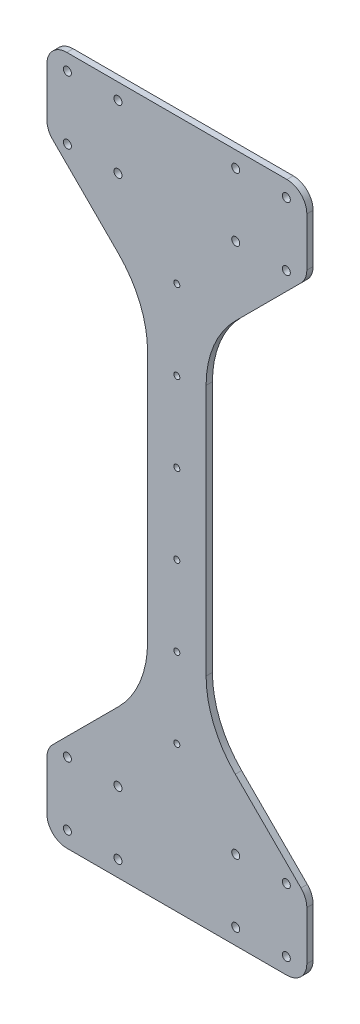
from build123d import *

# Parameters (mm, degrees)
BOSS_EXTRUDE1_DEPTH = 3.175
CUT_EXTRUDE1_DEPTH  = 10
SKETCH3_R           = 2.0193
BOSS_EXTRUDE2_DEPTH = 3.175
FILLET1_R           = 10
FILLET2_R           = 50
SKETCH4_R           = 2.02
CUT_EXTRUDE2_DEPTH  = 10
SKETCH5_R           = 1.5
CUT_EXTRUDE3_DEPTH  = 10


with BuildPart() as part:
    # Sketch1 → Boss-Extrude1 (new body)
    with BuildSketch(Plane.XY):
        Polygon((165.934536959, -16.66935), (157.315236959, -8.05005), (115.359952094, -8.05005), (89.959952094, -8.05005), (48.004667228, -8.05005), (39.385367228, -16.66935), (39.385367228, -40.05005), (39.385367228, -52.41105), (165.934536959, -56.67505), (165.934536959, -42.05005), align=None)
        with BuildLine():
            ThreePointArc((47.685367228, -44.38075), (49.704667228, -46.40005), (47.685367228, -48.41935))
            ThreePointArc((47.685367228, -48.41935), (45.666067228, -46.40005), (47.685367228, -44.38075))
        make_face(mode=Mode.SUBTRACT)
        with BuildLine():
            ThreePointArc((47.685367228, -12.63075), (49.704667228, -14.65005), (47.685367228, -16.66935))
            ThreePointArc((47.685367228, -16.66935), (45.666067228, -14.65005), (47.685367228, -12.63075))
        make_face(mode=Mode.SUBTRACT)
        with BuildLine():
            ThreePointArc((73.085367228, -44.38075), (75.104667228, -46.40005), (73.085367228, -48.41935))
            ThreePointArc((73.085367228, -48.41935), (71.066067228, -46.40005), (73.085367228, -44.38075))
        make_face(mode=Mode.SUBTRACT)
        with BuildLine():
            ThreePointArc((73.085367228, -12.63075), (75.104667228, -14.65005), (73.085367228, -16.66935))
            ThreePointArc((73.085367228, -16.66935), (71.066067228, -14.65005), (73.085367228, -12.63075))
        make_face(mode=Mode.SUBTRACT)
        with BuildLine():
            ThreePointArc((132.234536959, -44.38075), (134.253836959, -46.40005), (132.234536959, -48.41935))
            ThreePointArc((132.234536959, -48.41935), (130.215236959, -46.40005), (132.234536959, -44.38075))
        make_face(mode=Mode.SUBTRACT)
        with BuildLine():
            ThreePointArc((132.234536959, -12.63075), (134.253836959, -14.65005), (132.234536959, -16.66935))
            ThreePointArc((132.234536959, -16.66935), (130.215236959, -14.65005), (132.234536959, -12.63075))
        make_face(mode=Mode.SUBTRACT)
        with BuildLine():
            ThreePointArc((157.634536959, -44.38075), (159.653836959, -46.40005), (157.634536959, -48.41935))
            ThreePointArc((157.634536959, -48.41935), (155.615236959, -46.40005), (157.634536959, -44.38075))
        make_face(mode=Mode.SUBTRACT)
        with BuildLine():
            ThreePointArc((157.634536959, -12.63075), (159.653836959, -14.65005), (157.634536959, -16.66935))
            ThreePointArc((157.634536959, -16.66935), (155.615236959, -14.65005), (157.634536959, -12.63075))
        make_face(mode=Mode.SUBTRACT)
        Polygon((115.359952094, -8.05005), (157.315236959, -8.05005), (115.359952094, 33.905234866), align=None)
        Polygon((89.959952094, -8.05005), (115.359952094, -8.05005), (115.359952094, 33.905234866), (115.359952094, 203.394265134), (115.359952094, 245.34955), (89.959952094, 245.34955), (89.959952094, 203.394265134), (89.959952094, 33.905234866), align=None)
        Polygon((48.004667228, -8.05005), (89.959952094, -8.05005), (89.959952094, 33.905234866), align=None)
        Polygon((89.959952094, 245.34955), (115.359952094, 245.34955), (157.315236959, 245.34955), (165.934536959, 253.96885), (165.934536959, 279.34955), (165.934536959, 293.97455), (39.385367228, 289.71055), (39.385367228, 277.34955), (39.385367228, 253.96885), (48.004667228, 245.34955), align=None)
        with BuildLine():
            ThreePointArc((47.685367228, 253.96885), (49.704667228, 251.94955), (47.685367228, 249.93025))
            ThreePointArc((47.685367228, 249.93025), (45.666067228, 251.94955), (47.685367228, 253.96885))
        make_face(mode=Mode.SUBTRACT)
        with BuildLine():
            ThreePointArc((47.685367228, 285.71885), (49.704667228, 283.69955), (47.685367228, 281.68025))
            ThreePointArc((47.685367228, 281.68025), (45.666067228, 283.69955), (47.685367228, 285.71885))
        make_face(mode=Mode.SUBTRACT)
        with BuildLine():
            ThreePointArc((73.085367228, 253.96885), (75.104667228, 251.94955), (73.085367228, 249.93025))
            ThreePointArc((73.085367228, 249.93025), (71.066067228, 251.94955), (73.085367228, 253.96885))
        make_face(mode=Mode.SUBTRACT)
        with BuildLine():
            ThreePointArc((73.085367228, 285.71885), (75.104667228, 283.69955), (73.085367228, 281.68025))
            ThreePointArc((73.085367228, 281.68025), (71.066067228, 283.69955), (73.085367228, 285.71885))
        make_face(mode=Mode.SUBTRACT)
        with BuildLine():
            ThreePointArc((132.234536959, 253.96885), (134.253836959, 251.94955), (132.234536959, 249.93025))
            ThreePointArc((132.234536959, 249.93025), (130.215236959, 251.94955), (132.234536959, 253.96885))
        make_face(mode=Mode.SUBTRACT)
        with BuildLine():
            ThreePointArc((157.634536959, 253.96885), (159.653836959, 251.94955), (157.634536959, 249.93025))
            ThreePointArc((157.634536959, 249.93025), (155.615236959, 251.94955), (157.634536959, 253.96885))
        make_face(mode=Mode.SUBTRACT)
        with BuildLine():
            ThreePointArc((157.634536959, 285.71885), (159.653836959, 283.69955), (157.634536959, 281.68025))
            ThreePointArc((157.634536959, 281.68025), (155.615236959, 283.69955), (157.634536959, 285.71885))
        make_face(mode=Mode.SUBTRACT)
        Polygon((115.359952094, 245.34955), (115.359952094, 203.394265134), (157.315236959, 245.34955), align=None)
        Polygon((48.004667228, 245.34955), (89.959952094, 203.394265134), (89.959952094, 245.34955), align=None)
    extrude(amount=BOSS_EXTRUDE1_DEPTH)

    # Sketch2 → Cut-Extrude1 (cut)
    with BuildSketch(Plane.XY.offset(3.175)):
        Polygon((84.385367228, -52.41105), (39.385367228, -52.41105), (165.934536959, -56.67505), (165.934536959, -52.41105), (120.934536959, -52.41105), align=None)
        Polygon((120.934536959, 289.71055), (165.934536959, 289.71055), (165.934536959, 293.97455), (39.385367228, 289.71055), (84.385367228, 289.71055), align=None)
    extrude(amount=-CUT_EXTRUDE1_DEPTH, mode=Mode.SUBTRACT)

    # Sketch3 → Boss-Extrude2 (add)
    with BuildSketch(Plane.XY.offset(3.175)):
        Polygon((37.385367228, -15.840922875), (37.385367228, -54.41105), (167.934536959, -54.41105), (167.934536959, -15.840922875), (117.359952094, 34.73366199), (117.359952094, 202.56583801), (167.934536959, 253.140422875), (167.934536959, 291.71055), (37.385367228, 291.71055), (37.385367228, 253.140422875), (87.959952094, 202.56583801), (87.959952094, 34.73366199), align=None)
        with Locations((132.234536959, -46.40005)):
            Circle(SKETCH3_R, mode=Mode.SUBTRACT)
        with Locations((132.234536959, -14.65005)):
            Circle(SKETCH3_R, mode=Mode.SUBTRACT)
        with Locations((47.685367228, -14.65005)):
            Circle(SKETCH3_R, mode=Mode.SUBTRACT)
        with Locations((47.685367228, -46.40005)):
            Circle(SKETCH3_R, mode=Mode.SUBTRACT)
        with Locations((73.085367228, -46.40005)):
            Circle(SKETCH3_R, mode=Mode.SUBTRACT)
        with Locations((73.085367228, -14.65005)):
            Circle(SKETCH3_R, mode=Mode.SUBTRACT)
        with Locations((157.634536959, -14.65005)):
            Circle(SKETCH3_R, mode=Mode.SUBTRACT)
        with Locations((157.634536959, -46.40005)):
            Circle(SKETCH3_R, mode=Mode.SUBTRACT)
        with Locations((132.234536959, 251.94955)):
            Circle(SKETCH3_R, mode=Mode.SUBTRACT)
        with Locations((73.085367228, 251.94955)):
            Circle(SKETCH3_R, mode=Mode.SUBTRACT)
        with Locations((157.634536959, 251.94955)):
            Circle(SKETCH3_R, mode=Mode.SUBTRACT)
        with Locations((47.685367228, 251.94955)):
            Circle(SKETCH3_R, mode=Mode.SUBTRACT)
        with Locations((47.685367228, 283.69955)):
            Circle(SKETCH3_R, mode=Mode.SUBTRACT)
        with Locations((73.085367228, 283.69955)):
            Circle(SKETCH3_R, mode=Mode.SUBTRACT)
        with Locations((157.634536959, 283.69955)):
            Circle(SKETCH3_R, mode=Mode.SUBTRACT)
    extrude(amount=-BOSS_EXTRUDE2_DEPTH)

    # Fillet1
    fillet1_edges = [part.edges().sort_by_distance(p)[0] for p in [
        (37.385367228, -54.41105, 1.5875),
        (167.934536959, -54.41105, 1.5875),
        (167.934536959, -15.840922875, 1.5875),
        (167.934536959, 253.140422875, 1.5875),
        (167.934536959, 291.71055, 1.5875),
        (37.385367228, 291.71055, 1.5875),
        (37.385367228, 253.140422875, 1.5875),
        (37.385367228, -15.840922875, 1.5875),
    ]]
    fillet(fillet1_edges, radius=FILLET1_R)

    # Fillet2
    fillet2_edges = [part.edges().sort_by_distance(p)[0] for p in [
        (117.359952094, 34.73366199, 1.5875),
        (117.359952094, 202.56583801, 1.5875),
        (87.959952094, 202.56583801, 1.5875),
        (87.959952094, 34.73366199, 1.5875),
    ]]
    fillet(fillet2_edges, radius=FILLET2_R)

    # Sketch4 → Cut-Extrude2 (cut)
    with BuildSketch(Plane.XY.offset(3.175)):
        with Locations((132.234536959, 283.69955)):
            Circle(SKETCH4_R)
    extrude(amount=-CUT_EXTRUDE2_DEPTH, mode=Mode.SUBTRACT)

    # Sketch5 → Cut-Extrude3 (cut)
    with BuildSketch(Plane(origin=(0, 0, 0), x_dir=(-1, 0, 0), z_dir=(0, 0, -1))):
        with Locations((-102.659952094, 58.64975)):
            Circle(SKETCH5_R)
        with Locations((-102.659952094, 98.64975)):
            Circle(SKETCH5_R)
        with Locations((-102.659952094, 138.64975)):
            Circle(SKETCH5_R)
        with Locations((-102.659952094, 178.64975)):
            Circle(SKETCH5_R)
        with Locations((-102.659952094, 18.64975)):
            Circle(SKETCH5_R)
        with Locations((-102.659952094, 218.64975)):
            Circle(SKETCH5_R)
    extrude(amount=-CUT_EXTRUDE3_DEPTH, mode=Mode.SUBTRACT)


solid = part.part
